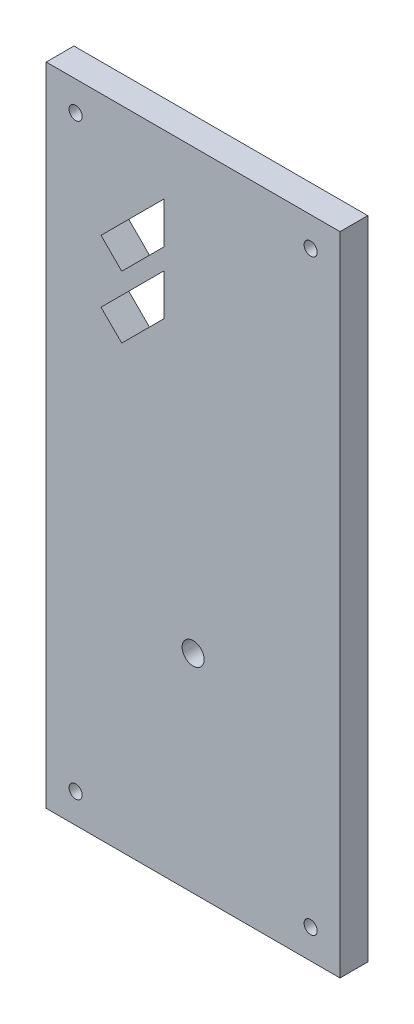
from build123d import *

# Parameters (mm, degrees)
SKETCH1_W           = 63.5
SKETCH1_H           = 139.7
SKETCH1_R           = 1.4224
SKETCH1_R_2         = 2.38125
BOSS_EXTRUDE1_DEPTH = 5.9944


with BuildPart() as part:
    # Sketch1 → Boss-Extrude1 (new body)
    with BuildSketch(Plane.XY):
        with Locations((31.75, 69.85)):
            Rectangle(SKETCH1_W, SKETCH1_H)
        with Locations((6.35, 133.35)):
            Circle(SKETCH1_R, mode=Mode.SUBTRACT)
        with Locations((57.15, 133.35)):
            Circle(SKETCH1_R, mode=Mode.SUBTRACT)
        with Locations((57.15, 6.35)):
            Circle(SKETCH1_R, mode=Mode.SUBTRACT)
        with Locations((6.35, 6.35)):
            Circle(SKETCH1_R, mode=Mode.SUBTRACT)
        with Locations((31.75, 44.8945)):
            Circle(SKETCH1_R_2, mode=Mode.SUBTRACT)
        Polygon((25.481826149, 104.411127028), (25.481826149, 113.369073478), (11.841725896, 99.728973225), (16.320699121, 95.25), align=None, mode=Mode.SUBTRACT)
        Polygon((25.481826149, 117.859201538), (25.481826149, 126.817147988), (11.841725896, 113.177047735), (16.320699121, 108.69807451), align=None, mode=Mode.SUBTRACT)
    extrude(amount=BOSS_EXTRUDE1_DEPTH)


solid = part.part
